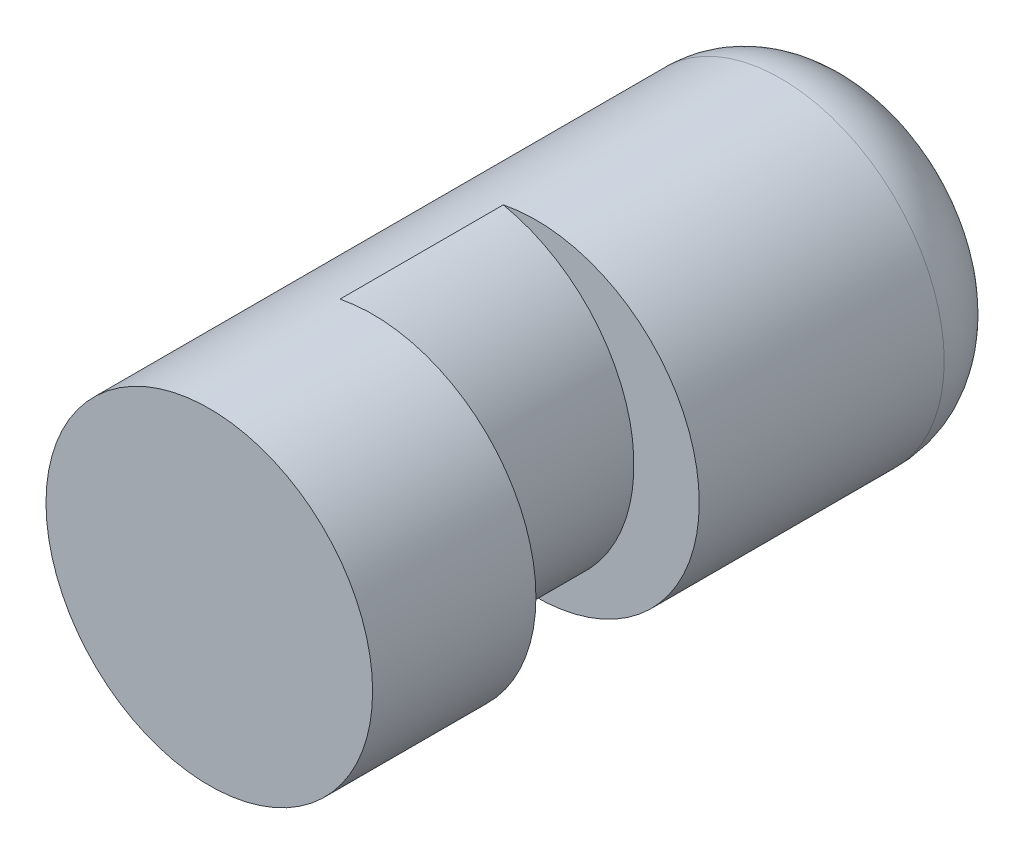
from build123d import *

# Parameters (mm, degrees)
SKETCH1_R          = 6.35
EXTRUDE1_DEPTH     = 25.4
CUT_EXTRUDE1_DEPTH = 6.35
FILLET1_R          = 3.175


with BuildPart() as part:
    # Sketch1 → Extrude1 (new body)
    with BuildSketch(Plane.XY):
        with Locations((-109.908874461, 962.175)):
            Circle(SKETCH1_R)
    extrude(amount=-EXTRUDE1_DEPTH)

    # Sketch2 → Cut-Extrude1 (cut)
    with BuildSketch(Plane(origin=(0, 0, -6.35), x_dir=(-1, 0, 0), z_dir=(0, 0, -1))):
        with BuildLine():
            ThreePointArc((111.178874461, 968.396703947), (106.098874461, 962.175), (111.178874461, 955.953296053))
            ThreePointArc((111.178874461, 955.953296053), (103.558874461, 962.175), (111.178874461, 968.396703947))
        make_face()
    extrude(amount=CUT_EXTRUDE1_DEPTH, mode=Mode.SUBTRACT)

    # Fillet1
    fillet1_edges = [part.edges().sort_by_distance(p)[0] for p in [
        (-116.258874461, 962.175, -25.4),
    ]]
    fillet(fillet1_edges, radius=FILLET1_R)


solid = part.part
